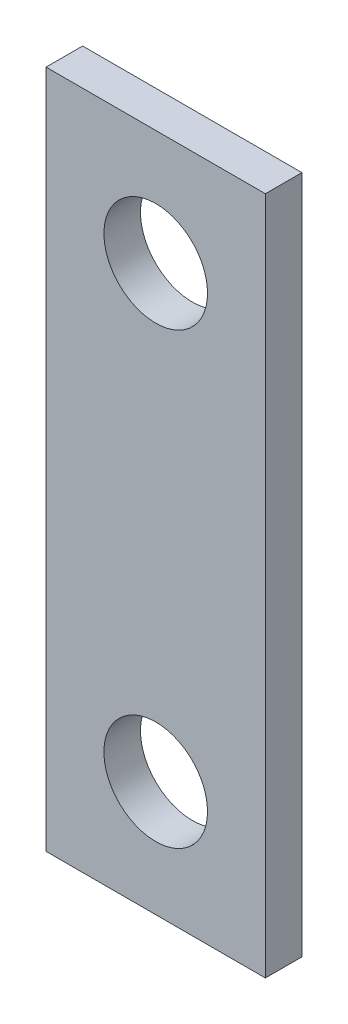
from build123d import *

# Parameters (mm, degrees)
SKETCH1_W                                = 19.05
SKETCH1_H                                = 59
BOSS_EXTRUDE1_DEPTH                      = 3.175
CELL_MODULE_TERMINAL_M8_CLEARANCE_HOLE_D = 9


with BuildPart() as part:
    # Sketch1 → Boss-Extrude1 (new body)
    with BuildSketch(Plane.XY):
        with Locations((17, -19.5)):
            Rectangle(SKETCH1_W, SKETCH1_H)
    extrude(amount=BOSS_EXTRUDE1_DEPTH)

    # Cell Module Terminal M8 Clearance Hole (through all)
    with Locations(Plane.XY.offset(3.175)):
        with Locations((17, 0), (17, -39)):
            Hole(CELL_MODULE_TERMINAL_M8_CLEARANCE_HOLE_D / 2)


solid = part.part
